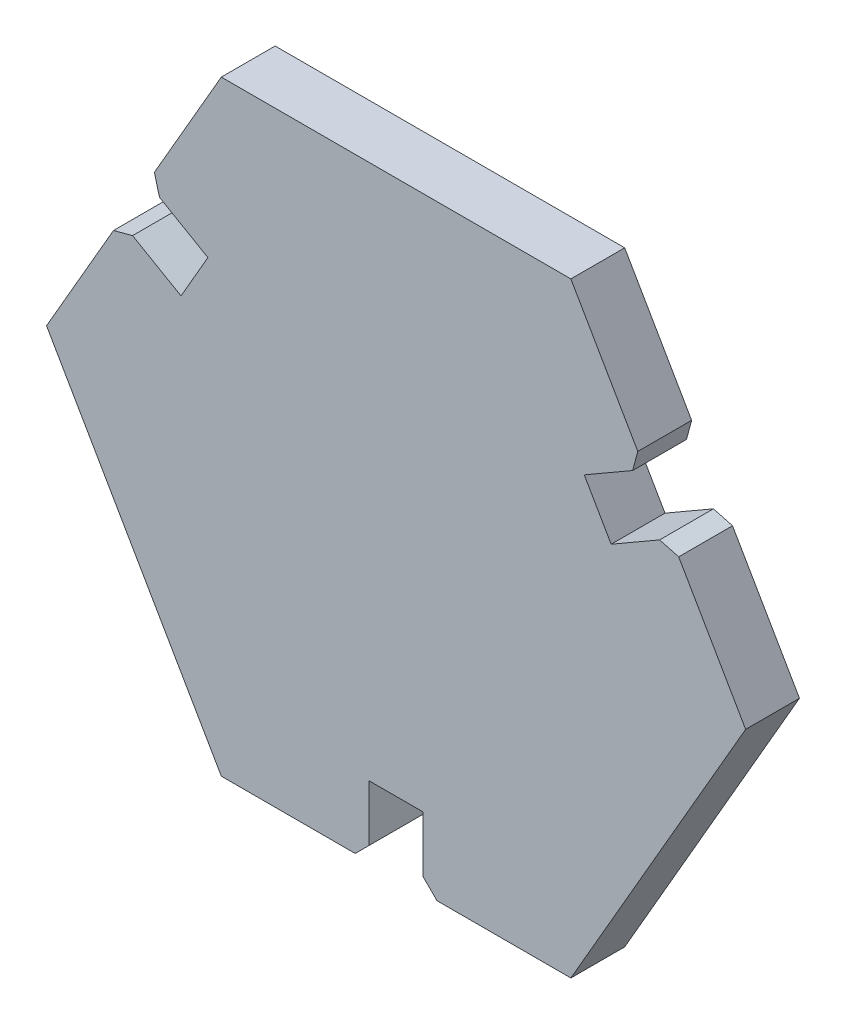
from build123d import *

# Parameters (mm, degrees)
BOSS_EXTRUDE1_DEPTH = 3.85
CHAMFER1_SIZE       = 1


with BuildPart() as part:
    # Sketch1 → Boss-Extrude1 (new body)
    with BuildSketch(Plane.XY):
        Polygon((25, 0), (19.7125, 9.158218645), (15.382372981, 6.658218645), (13.457372981, 9.99241645), (17.7875, 12.49241645), (12.5, 21.650635095), (-12.5, 21.650635095), (-17.7875, 12.49241645), (-13.457372981, 9.99241645), (-15.382372981, 6.658218645), (-19.7125, 9.158218645), (-25, 0), (-12.5, -21.650635095), (-1.925, -21.650635095), (-1.925, -16.650635095), (1.925, -16.650635095), (1.925, -21.650635095), (12.5, -21.650635095), align=None)
    extrude(amount=BOSS_EXTRUDE1_DEPTH)

    # Chamfer1
    chamfer1_edges = [part.edges().sort_by_distance(p)[0] for p in [
        (1.925, -21.650635095, 1.925),
        (-1.925, -21.650635095, 1.925),
        (-19.7125, 9.158218645, 1.925),
        (-17.7875, 12.49241645, 1.925),
        (17.7875, 12.49241645, 1.925),
        (19.7125, 9.158218645, 1.925),
    ]]
    chamfer(chamfer1_edges, length=CHAMFER1_SIZE)


solid = part.part
